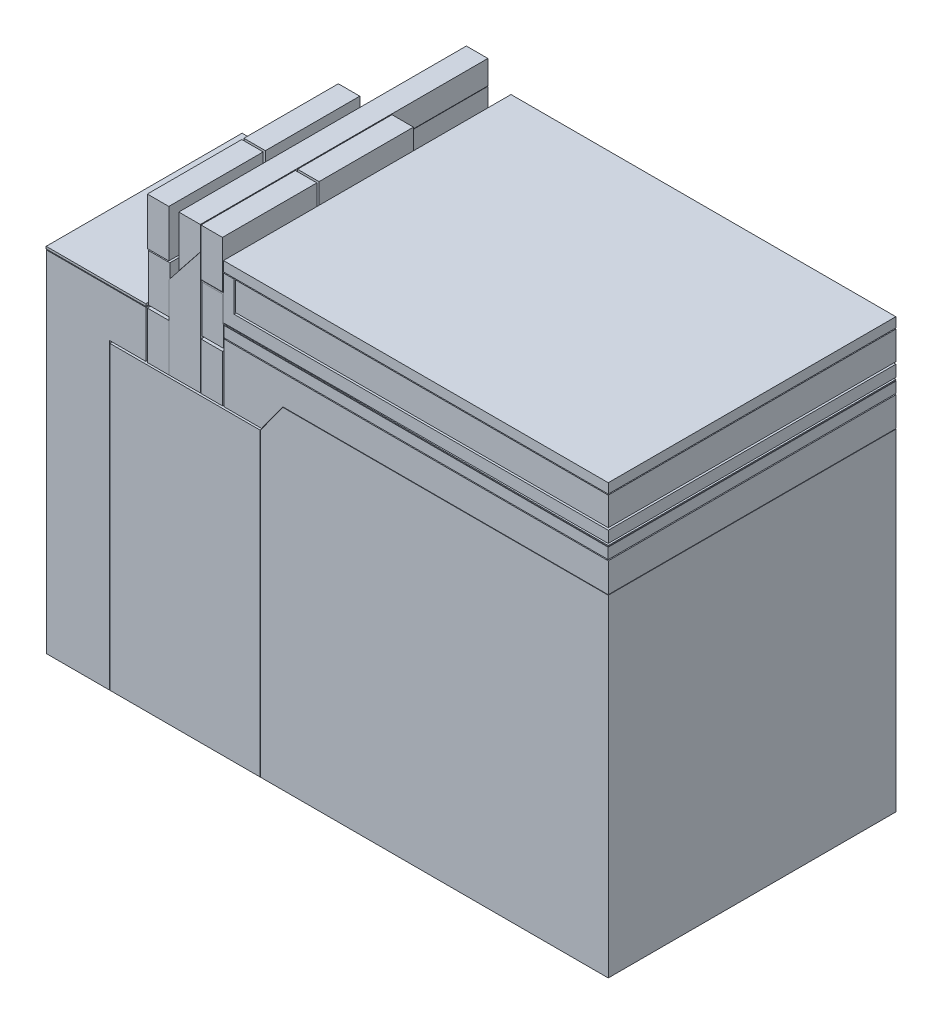
from build123d import *

# Parameters (mm, degrees)
SKETCH3_W        = 100
SKETCH3_H        = 220
EXTRUDE2_DEPTH   = 440
EXTRUDE2_2_DEPTH = 440
SKETCH4_W        = 440
SKETCH4_H        = 220
EXTRUDE3_DEPTH   = 100
EXTRUDE3_2_DEPTH = 100
SKETCH5_W        = 440
SKETCH5_H        = 220
EXTRUDE4_DEPTH   = 100
EXTRUDE4_2_DEPTH = 100
SKETCH6_W        = 215
SKETCH6_H        = 220
EXTRUDE5_DEPTH   = 100
SKETCH6_W_2      = 440
EXTRUDE5_2_DEPTH = 100
EXTRUDE5_3_DEPTH = 100
SKETCH7_W        = 215
SKETCH7_H        = 220
EXTRUDE6_DEPTH   = 100
SKETCH7_W_2      = 440
EXTRUDE6_2_DEPTH = 100
EXTRUDE6_3_DEPTH = 100
SKETCH8_W        = 440
SKETCH8_H        = 220
EXTRUDE7_DEPTH   = 100
EXTRUDE7_2_DEPTH = 100
SKETCH9_W        = 440
SKETCH9_H        = 220
EXTRUDE8_DEPTH   = 100
EXTRUDE8_2_DEPTH = 100
EXTRUDE9_DEPTH   = 1340
EXTRUDE11_DEPTH  = 1340
EXTRUDE12_DEPTH  = 1340
SKETCH24_W       = 1790.789504891
SKETCH24_H       = 50
EXTRUDE22_DEPTH  = 1340
EXTRUDE24_DEPTH  = 1340
SKETCH20_W       = 700
SKETCH20_H       = 1400
EXTRUDE18_DEPTH  = 1400
EXTRUDE19_DEPTH  = 913
EXTRUDE20_DEPTH  = 1340
SKETCH23_W       = 464.076833361
SKETCH23_H       = 10.585570604
EXTRUDE21_DEPTH  = 913
EXTRUDE26_DEPTH  = 1340
SKETCH28_W       = 1737.031845103
SKETCH28_H       = 131.613655514
EXTRUDE27_DEPTH  = 1340
SKETCH29_W       = 1793.161552428
SKETCH29_H       = 45.780441011
EXTRUDE28_DEPTH  = 1340


with BuildPart() as part:
    # Sketch3 → Extrude2 (new body)
    with BuildSketch(Plane.XY):
        with Locations((-825, 470)):
            Rectangle(SKETCH3_W, SKETCH3_H)
    extrude(amount=-EXTRUDE2_DEPTH)


with BuildPart() as body_2:
    # Sketch3 → Extrude2 2 (new body)
    with BuildSketch(Plane.XY):
        with Locations((-575, 470)):
            Rectangle(SKETCH3_W, SKETCH3_H)
    extrude(amount=-EXTRUDE2_2_DEPTH)


with BuildPart() as body_3:
    # Sketch4 → Extrude3 (new body)
    with BuildSketch(Plane(origin=(-525, 0, 0), x_dir=(0, 0, -1), z_dir=(1, 0, 0))):
        with Locations((670, 470)):
            Rectangle(SKETCH4_W, SKETCH4_H)
    extrude(amount=-EXTRUDE3_DEPTH)


with BuildPart() as body_4:
    # Sketch4 → Extrude3 2 (new body)
    with BuildSketch(Plane(origin=(-525, 0, 0), x_dir=(0, 0, -1), z_dir=(1, 0, 0))):
        with Locations((1120, 470)):
            Rectangle(SKETCH4_W, SKETCH4_H)
    extrude(amount=-EXTRUDE3_2_DEPTH)


with BuildPart() as body_5:
    # Sketch5 → Extrude4 (new body)
    with BuildSketch(Plane.ZY.offset(875)):
        with Locations((-670, 470)):
            Rectangle(SKETCH5_W, SKETCH5_H)
    extrude(amount=-EXTRUDE4_DEPTH)


with BuildPart() as body_6:
    # Sketch5 → Extrude4 2 (new body)
    with BuildSketch(Plane.ZY.offset(875)):
        with Locations((-1120, 470)):
            Rectangle(SKETCH5_W, SKETCH5_H)
    extrude(amount=-EXTRUDE4_2_DEPTH)


with BuildPart() as body_7:
    # Sketch6 → Extrude5 (new body)
    with BuildSketch(Plane.ZY.offset(875)):
        with Locations((-112.153388306, 700)):
            Rectangle(SKETCH6_W, SKETCH6_H)
    extrude(amount=-EXTRUDE5_DEPTH)


with BuildPart() as body_8:
    # Sketch6 → Extrude5 2 (new body)
    with BuildSketch(Plane.ZY.offset(875)):
        with Locations((-449.653388306, 700)):
            Rectangle(SKETCH6_W_2, SKETCH6_H)
    extrude(amount=-EXTRUDE5_2_DEPTH)


with BuildPart() as body_9:
    # Sketch6 → Extrude5 3 (new body)
    with BuildSketch(Plane.ZY.offset(875)):
        with Locations((-899.653388306, 700)):
            Rectangle(SKETCH6_W_2, SKETCH6_H)
    extrude(amount=-EXTRUDE5_3_DEPTH)


with BuildPart() as body_10:
    # Sketch7 → Extrude6 (new body)
    with BuildSketch(Plane(origin=(-525, 0, 0), x_dir=(0, 0, -1), z_dir=(1, 0, 0))):
        with Locations((112.153388306, 700)):
            Rectangle(SKETCH7_W, SKETCH7_H)
    extrude(amount=-EXTRUDE6_DEPTH)


with BuildPart() as body_11:
    # Sketch7 → Extrude6 2 (new body)
    with BuildSketch(Plane(origin=(-525, 0, 0), x_dir=(0, 0, -1), z_dir=(1, 0, 0))):
        with Locations((449.653388306, 700)):
            Rectangle(SKETCH7_W_2, SKETCH7_H)
    extrude(amount=-EXTRUDE6_2_DEPTH)


with BuildPart() as body_12:
    # Sketch7 → Extrude6 3 (new body)
    with BuildSketch(Plane(origin=(-525, 0, 0), x_dir=(0, 0, -1), z_dir=(1, 0, 0))):
        with Locations((899.653388306, 700)):
            Rectangle(SKETCH7_W_2, SKETCH7_H)
    extrude(amount=-EXTRUDE6_3_DEPTH)


with BuildPart() as body_13:
    # Sketch8 → Extrude7 (new body)
    with BuildSketch(Plane(origin=(-525, 0, 0), x_dir=(0, 0, -1), z_dir=(1, 0, 0))):
        with Locations((220, 930)):
            Rectangle(SKETCH8_W, SKETCH8_H)
    extrude(amount=-EXTRUDE7_DEPTH)


with BuildPart() as body_14:
    # Sketch8 → Extrude7 2 (new body)
    with BuildSketch(Plane(origin=(-525, 0, 0), x_dir=(0, 0, -1), z_dir=(1, 0, 0))):
        with Locations((670, 930)):
            Rectangle(SKETCH8_W, SKETCH8_H)
    extrude(amount=-EXTRUDE7_2_DEPTH)


with BuildPart() as body_15:
    # Sketch9 → Extrude8 (new body)
    with BuildSketch(Plane.ZY.offset(875)):
        with Locations((-220, 930)):
            Rectangle(SKETCH9_W, SKETCH9_H)
    extrude(amount=-EXTRUDE8_DEPTH)


with BuildPart() as body_16:
    # Sketch9 → Extrude8 2 (new body)
    with BuildSketch(Plane.ZY.offset(875)):
        with Locations((-670, 930)):
            Rectangle(SKETCH9_W, SKETCH9_H)
    extrude(amount=-EXTRUDE8_2_DEPTH)


with BuildPart() as body_17:
    # Sketch10 → Extrude9 (new body)
    with BuildSketch(Plane.XY):
        Polygon((-627.907694715, 360.835028646), (-627.907694715, 928.472526147), (-773.381678262, 745.647276183), (-773.381678262, 360), align=None)
    extrude(amount=-EXTRUDE9_DEPTH)


with BuildPart() as body_18:
    # Sketch11 → Extrude11 (new body)
    with BuildSketch(Plane.XY):
        Polygon((-628.099045308, 929.879079521), (-628.099045308, 1040.628318336), (-728.439314987, 1040.628318336), (-728.439314987, 803.509684084), align=None)
    extrude(amount=-EXTRUDE11_DEPTH)


with BuildPart() as body_19:
    # Sketch12 → Extrude12 (new body)
    with BuildSketch(Plane.XY):
        Polygon((-517.640765265, 633.76634965), (-517.640765265, 360.14636084), (-342.640765265, 360.14636084), (-244.026326381, 496.956355245), (98.614438884, 496.956355245), (1272.816242878, 496.956355245), (1272.816242878, 633.76634965), align=None)
    extrude(amount=-EXTRUDE12_DEPTH)


with BuildPart() as body_20:
    # Sketch24 → Extrude22 (new body)
    with BuildSketch(Plane.XY):
        with Locations((377.22229043, 663.480473248)):
            Rectangle(SKETCH24_W, SKETCH24_H)
    extrude(amount=-EXTRUDE22_DEPTH)


with BuildPart() as body_21:
    # Sketch25 → Extrude24 (new body)
    with BuildSketch(Plane.XY):
        Polygon((-625, 818.536958585), (-521.130551864, 818.536958585), (-521.130551864, 695.427590061), (1272.816242878, 695.427590061), (1272.816242878, 690.631876529), (-524.01067712, 690.631876529), (-524.01067712, 811.70047307), (-625, 811.70047307), align=None)
    extrude(amount=-EXTRUDE24_DEPTH)


with BuildPart() as body_22:
    # Sketch20 → Extrude18 (new body)
    with BuildSketch(Plane.XY):
        with Locations((-700, -350)):
            Rectangle(SKETCH20_W, SKETCH20_H)
    extrude(amount=-EXTRUDE18_DEPTH)


with BuildPart() as body_23:
    # Sketch21 → Extrude19 (new body)
    with BuildSketch(Plane.XY):
        Polygon((-881.995314685, 360.986926343), (-881.995314685, 579.27077558), (-1345.793666931, 579.27077558), (-1345.793666931, -1050), (-1052.033102721, -1050), (-1052.033102721, 360.986926343), align=None)
    extrude(amount=-EXTRUDE19_DEPTH)


with BuildPart() as body_24:
    # Sketch22 → Extrude20 (new body)
    with BuildSketch(Plane.XY):
        Polygon((-348.369017237, -1049.885916156), (-348.369017237, 349.927493333), (-243.585812421, 494.83218617), (1272.816242878, 494.83218617), (1272.816242878, -1049.885916156), align=None)
    extrude(amount=-EXTRUDE20_DEPTH)


with BuildPart() as body_25:
    # Sketch23 → Extrude21 (new body)
    with BuildSketch(Plane.XY):
        with Locations((-1114.315671992, 588.122810898)):
            Rectangle(SKETCH23_W, SKETCH23_H)
    extrude(amount=-EXTRUDE21_DEPTH)


with BuildPart() as body_26:
    # Sketch27 → Extrude26 (new body)
    with BuildSketch(Plane.XY):
        Polygon((-519.745602556, 697.610790311), (-519.745602556, 898.678271384), (-470.865525198, 898.678271384), (-470.865525198, 756.982274323), (1272.816242878, 756.982274323), (1272.816242878, 703.651896533), align=None)
    extrude(amount=-EXTRUDE26_DEPTH)


with BuildPart() as body_27:
    # Sketch28 → Extrude27 (new body)
    with BuildSketch(Plane.XY):
        with Locations((404.300320327, 832.871443627)):
            Rectangle(SKETCH28_W, SKETCH28_H)
    extrude(amount=-EXTRUDE27_DEPTH)


with BuildPart() as body_28:
    # Sketch29 → Extrude28 (new body)
    with BuildSketch(Plane.XY):
        with Locations((376.235466664, 925.998002716)):
            Rectangle(SKETCH29_W, SKETCH29_H)
    extrude(amount=-EXTRUDE28_DEPTH)


solid = Compound([part.part, body_2.part, body_3.part, body_4.part, body_5.part, body_6.part, body_7.part, body_8.part, body_9.part, body_10.part, body_11.part, body_12.part, body_13.part, body_14.part, body_15.part, body_16.part, body_17.part, body_18.part, body_19.part, body_20.part, body_21.part, body_22.part, body_23.part, body_24.part, body_25.part, body_26.part, body_27.part, body_28.part])
